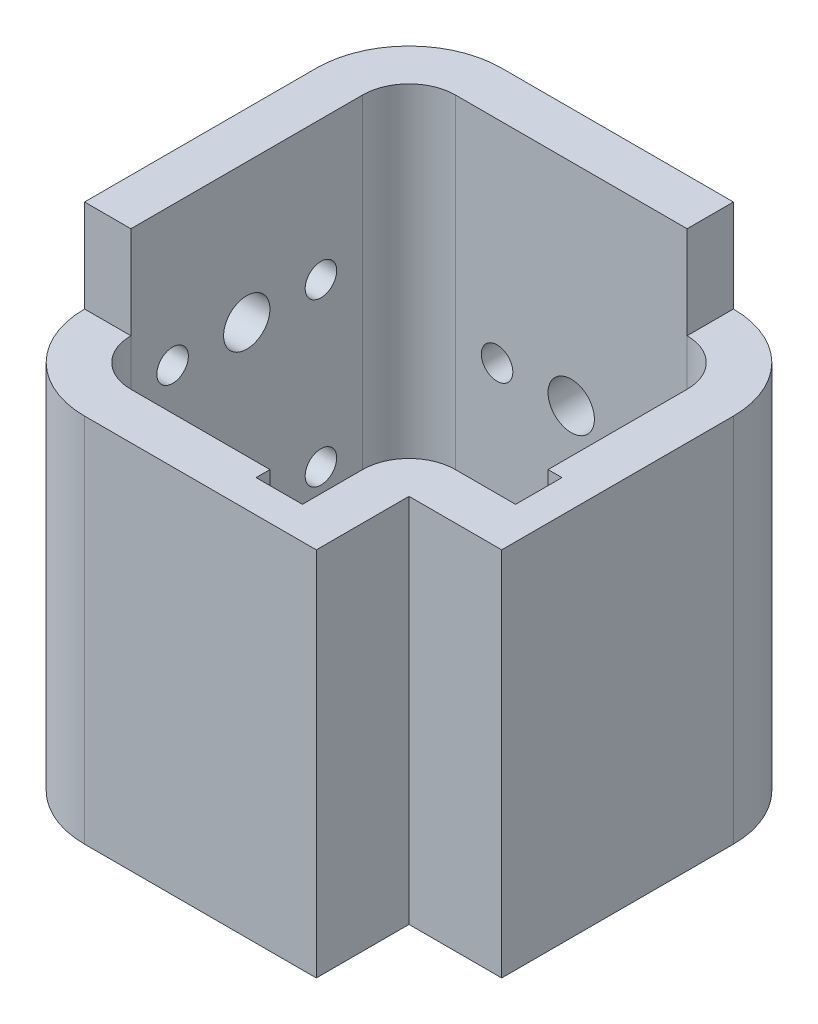
from build123d import *

# Parameters (mm, degrees)
BOSS_EXTRUDE1_DEPTH      = 54.6167
BOSS_EXTRUDE1_DEPTH_BACK = 45.3833
SKETCH2_W                = 20
SKETCH2_H                = 20
CUT_EXTRUDE1_DEPTH       = 91
SKETCH3_W                = 20
SKETCH3_H                = 20
CUT_EXTRUDE2_DEPTH       = 91
BOSS_EXTRUDE2_START      = -45.3833
SKETCH1_5_W              = 3
SKETCH1_5_H              = 10
SKETCH1_5_W_2            = 10
SKETCH1_5_H_2            = 3
BOSS_EXTRUDE2_DEPTH      = 80
CUT_EXTRUDE3_REACH       = 92
SKETCH5_R                = 5
SKETCH5_R_2              = 3.4
CUT_EXTRUDE4_REACH       = 92
SKETCH4_R                = 5
SKETCH4_R_2              = 3.4


with BuildPart() as part:
    # Sketch1 → Boss-Extrude1 (new body, two sides)
    with BuildSketch(Plane(origin=(0, 0, 0), x_dir=(1, 0, 0), z_dir=(0, 1, 0))) as boss_extrude1_sk:
        with BuildLine():
            ThreePointArc((45, 25), (39.142135624, 39.142135624), (25, 45))
            Line((25, 45), (-25, 45))
            ThreePointArc((-25, 45), (-39.142135624, 39.142135624), (-45, 25))
            Line((-45, 25), (-45, -25))
            ThreePointArc((-45, -25), (-39.142135624, -39.142135624), (-25, -45))
            Line((-25, -45), (25, -45))
            Line((25, -45), (25, -38))
            Line((25, -38), (15, -38))
            Line((15, -38), (5, -38))
            Line((5, -38), (5, -35))
            Line((5, -35), (-25, -35))
            ThreePointArc((-25, -35), (-32.071067812, -32.071067812), (-35, -25))
            Line((-35, -25), (-35, 25))
            ThreePointArc((-35, 25), (-32.071067812, 32.071067812), (-25, 35))
            Line((-25, 35), (25, 35))
            ThreePointArc((25, 35), (32.071067812, 32.071067812), (35, 25))
            Line((35, 25), (35, -5))
            Line((35, -5), (38, -5))
            Line((38, -5), (38, -15))
            Line((38, -15), (38, -25))
            Line((38, -25), (45, -25))
            Line((45, -25), (45, 25))
        make_face()
    extrude(amount=BOSS_EXTRUDE1_DEPTH)
    extrude(boss_extrude1_sk.sketch, amount=-BOSS_EXTRUDE1_DEPTH_BACK)

    # Sketch2 → Cut-Extrude1 (cut, through all)
    with BuildSketch(Plane(origin=(0, 0, -45), x_dir=(-1, 0, 0), z_dir=(0, 0, -1))):
        with Locations((-35, 44.616700276)):
            Rectangle(SKETCH2_W, SKETCH2_H)
    extrude(amount=-CUT_EXTRUDE1_DEPTH, mode=Mode.SUBTRACT)

    # Sketch3 → Cut-Extrude2 (cut, through all)
    with BuildSketch(Plane.ZY.offset(45)):
        with Locations((35, 44.616700276)):
            Rectangle(SKETCH3_W, SKETCH3_H)
    extrude(amount=-CUT_EXTRUDE2_DEPTH, mode=Mode.SUBTRACT)

    # Sketch1_5 → Boss-Extrude2 (add)
    with BuildSketch(Plane(origin=(0, 0, 0), x_dir=(1, 0, 0), z_dir=(0, 1, 0)).offset(BOSS_EXTRUDE2_START)):
        with BuildLine():
            Line((25, -25), (35, -25))
            Line((35, -25), (35, -15))
            Line((35, -15), (25, -15))
            ThreePointArc((25, -15), (17.928932188, -17.928932188), (15, -25))
            Line((15, -25), (15, -35))
            Line((15, -35), (25, -35))
            Line((25, -35), (25, -25))
        make_face()
        with Locations((36.5, -20)):
            Rectangle(SKETCH1_5_W, SKETCH1_5_H)
        with Locations((20, -36.5)):
            Rectangle(SKETCH1_5_W_2, SKETCH1_5_H_2)
    extrude(amount=BOSS_EXTRUDE2_DEPTH)

    # Sketch5 → Cut-Extrude3 (cut, up to next)
    with BuildSketch(Plane(origin=(0, 0, -45), x_dir=(-1, 0, 0), z_dir=(0, 0, -1)), mode=Mode.PRIVATE) as cut_extrude3_sk1:
        with Locations((0, 9.016700277)):
            Circle(SKETCH5_R)
    cut_extrude3_tool1 = extrude(cut_extrude3_sk1.sketch, amount=-CUT_EXTRUDE3_REACH, mode=Mode.PRIVATE) & part.part
    add(cut_extrude3_tool1.solids().sort_by_distance((0, 9.0167, -45))[0], mode=Mode.SUBTRACT)
    # Sketch5 → Cut-Extrude3 (cut, up to next)
    with BuildSketch(Plane(origin=(0, 0, -45), x_dir=(-1, 0, 0), z_dir=(0, 0, -1)), mode=Mode.PRIVATE) as cut_extrude3_sk2:
        with Locations((0, -25.983299723)):
            Circle(SKETCH5_R)
    cut_extrude3_tool2 = extrude(cut_extrude3_sk2.sketch, amount=-CUT_EXTRUDE3_REACH, mode=Mode.PRIVATE) & part.part
    add(cut_extrude3_tool2.solids().sort_by_distance((0, -25.9833, -45))[0], mode=Mode.SUBTRACT)
    # Sketch5 → Cut-Extrude3 (cut, up to next)
    with BuildSketch(Plane(origin=(0, 0, -45), x_dir=(-1, 0, 0), z_dir=(0, 0, -1)), mode=Mode.PRIVATE) as cut_extrude3_sk3:
        with Locations((16, -25.983299723)):
            Circle(SKETCH5_R_2)
    cut_extrude3_tool3 = extrude(cut_extrude3_sk3.sketch, amount=-CUT_EXTRUDE3_REACH, mode=Mode.PRIVATE) & part.part
    add(cut_extrude3_tool3.solids().sort_by_distance((-16, -25.9833, -45))[0], mode=Mode.SUBTRACT)
    # Sketch5 → Cut-Extrude3 (cut, up to next)
    with BuildSketch(Plane(origin=(0, 0, -45), x_dir=(-1, 0, 0), z_dir=(0, 0, -1)), mode=Mode.PRIVATE) as cut_extrude3_sk4:
        with Locations((-16, -25.983299723)):
            Circle(SKETCH5_R_2)
    cut_extrude3_tool4 = extrude(cut_extrude3_sk4.sketch, amount=-CUT_EXTRUDE3_REACH, mode=Mode.PRIVATE) & part.part
    add(cut_extrude3_tool4.solids().sort_by_distance((16, -25.9833, -45))[0], mode=Mode.SUBTRACT)
    # Sketch5 → Cut-Extrude3 (cut, up to next)
    with BuildSketch(Plane(origin=(0, 0, -45), x_dir=(-1, 0, 0), z_dir=(0, 0, -1)), mode=Mode.PRIVATE) as cut_extrude3_sk5:
        with Locations((-16, 9.016700277)):
            Circle(SKETCH5_R_2)
    cut_extrude3_tool5 = extrude(cut_extrude3_sk5.sketch, amount=-CUT_EXTRUDE3_REACH, mode=Mode.PRIVATE) & part.part
    add(cut_extrude3_tool5.solids().sort_by_distance((16, 9.0167, -45))[0], mode=Mode.SUBTRACT)
    # Sketch5 → Cut-Extrude3 (cut, up to next)
    with BuildSketch(Plane(origin=(0, 0, -45), x_dir=(-1, 0, 0), z_dir=(0, 0, -1)), mode=Mode.PRIVATE) as cut_extrude3_sk6:
        with Locations((16, 9.016700277)):
            Circle(SKETCH5_R_2)
    cut_extrude3_tool6 = extrude(cut_extrude3_sk6.sketch, amount=-CUT_EXTRUDE3_REACH, mode=Mode.PRIVATE) & part.part
    add(cut_extrude3_tool6.solids().sort_by_distance((-16, 9.0167, -45))[0], mode=Mode.SUBTRACT)

    # Sketch4 → Cut-Extrude4 (cut, up to next)
    with BuildSketch(Plane.ZY.offset(45), mode=Mode.PRIVATE) as cut_extrude4_sk1:
        with Locations((0.001556396, 24.616700277)):
            Circle(SKETCH4_R)
    cut_extrude4_tool1 = extrude(cut_extrude4_sk1.sketch, amount=-CUT_EXTRUDE4_REACH, mode=Mode.PRIVATE) & part.part
    add(cut_extrude4_tool1.solids().sort_by_distance((-45, 24.6167, 0.001556))[0], mode=Mode.SUBTRACT)
    # Sketch4 → Cut-Extrude4 (cut, up to next)
    with BuildSketch(Plane.ZY.offset(45), mode=Mode.PRIVATE) as cut_extrude4_sk2:
        with Locations((0.001556396, -10.383299723)):
            Circle(SKETCH4_R)
    cut_extrude4_tool2 = extrude(cut_extrude4_sk2.sketch, amount=-CUT_EXTRUDE4_REACH, mode=Mode.PRIVATE) & part.part
    add(cut_extrude4_tool2.solids().sort_by_distance((-45, -10.3833, 0.001556))[0], mode=Mode.SUBTRACT)
    # Sketch4 → Cut-Extrude4 (cut, up to next)
    with BuildSketch(Plane.ZY.offset(45), mode=Mode.PRIVATE) as cut_extrude4_sk3:
        with Locations((16.001556396, -10.383299723)):
            Circle(SKETCH4_R_2)
    cut_extrude4_tool3 = extrude(cut_extrude4_sk3.sketch, amount=-CUT_EXTRUDE4_REACH, mode=Mode.PRIVATE) & part.part
    add(cut_extrude4_tool3.solids().sort_by_distance((-45, -10.3833, 16.001556))[0], mode=Mode.SUBTRACT)
    # Sketch4 → Cut-Extrude4 (cut, up to next)
    with BuildSketch(Plane.ZY.offset(45), mode=Mode.PRIVATE) as cut_extrude4_sk4:
        with Locations((-15.998443604, -10.383299723)):
            Circle(SKETCH4_R_2)
    cut_extrude4_tool4 = extrude(cut_extrude4_sk4.sketch, amount=-CUT_EXTRUDE4_REACH, mode=Mode.PRIVATE) & part.part
    add(cut_extrude4_tool4.solids().sort_by_distance((-45, -10.3833, -15.998444))[0], mode=Mode.SUBTRACT)
    # Sketch4 → Cut-Extrude4 (cut, up to next)
    with BuildSketch(Plane.ZY.offset(45), mode=Mode.PRIVATE) as cut_extrude4_sk5:
        with Locations((16.001556396, 24.616700277)):
            Circle(SKETCH4_R_2)
    cut_extrude4_tool5 = extrude(cut_extrude4_sk5.sketch, amount=-CUT_EXTRUDE4_REACH, mode=Mode.PRIVATE) & part.part
    add(cut_extrude4_tool5.solids().sort_by_distance((-45, 24.6167, 16.001556))[0], mode=Mode.SUBTRACT)
    # Sketch4 → Cut-Extrude4 (cut, up to next)
    with BuildSketch(Plane.ZY.offset(45), mode=Mode.PRIVATE) as cut_extrude4_sk6:
        with Locations((-15.998443604, 24.616700277)):
            Circle(SKETCH4_R_2)
    cut_extrude4_tool6 = extrude(cut_extrude4_sk6.sketch, amount=-CUT_EXTRUDE4_REACH, mode=Mode.PRIVATE) & part.part
    add(cut_extrude4_tool6.solids().sort_by_distance((-45, 24.6167, -15.998444))[0], mode=Mode.SUBTRACT)


solid = part.part
